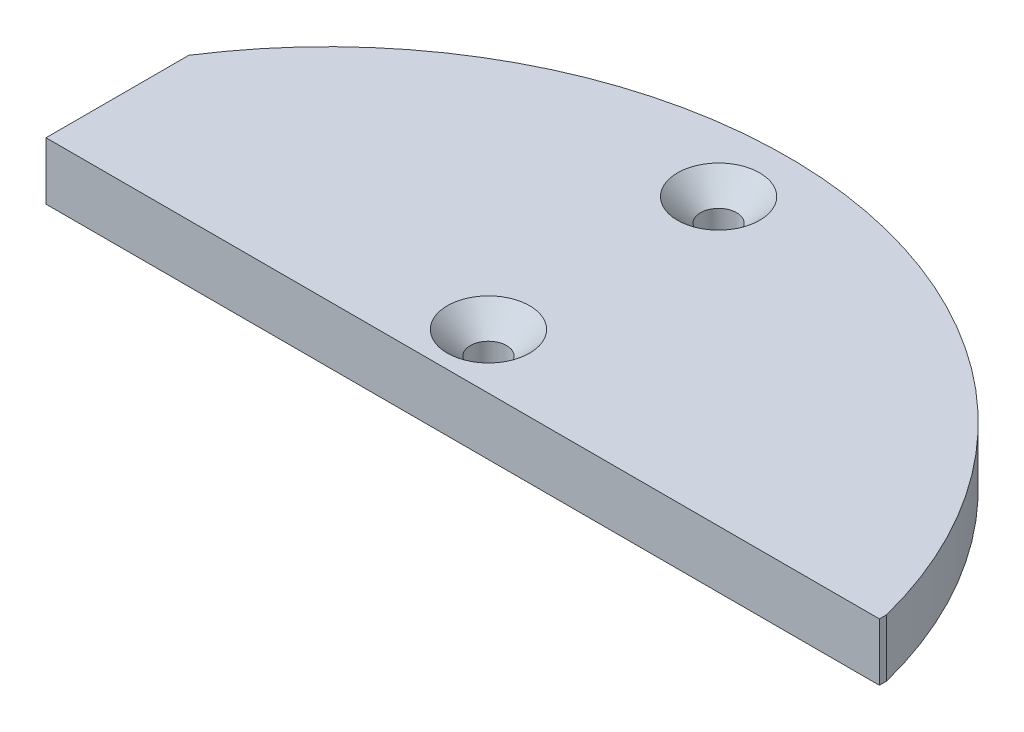
from build123d import *

# Parameters (mm, degrees)
SKETCH1_R           = 2
BOSS_EXTRUDE1_DEPTH = 6.35
CHAMFER1_SIZE       = 2.54
CUT_EXTRUDE1_DEPTH  = 4.7625
FILLET1_R           = 4
FILLET2_R           = 2


with BuildPart() as part:
    # Sketch1 → Boss-Extrude1 (new body)
    with BuildSketch(Plane(origin=(0, 0, 0), x_dir=(1, 0, 0), z_dir=(0, 1, 0))):
        with BuildLine():
            Line((-42.746, 11.684), (47.586884748, 11.684))
            Line((47.586884748, 11.684), (47.586884748, 17.78))
            ThreePointArc((47.586884748, 17.78), (31.011055518, 40.236232871), (5.073646026, 50.546))
            Line((5.073646026, 50.546), (-5.073646026, 50.546))
            ThreePointArc((-5.073646026, 50.546), (-26.552841725, 43.308043091), (-42.746, 27.448487827))
            Line((-42.746, 27.448487827), (-42.746, 11.684))
        make_face()
        with Locations((0, 17.78)):
            Circle(SKETCH1_R, mode=Mode.SUBTRACT)
        with Locations((0, 43.18)):
            Circle(SKETCH1_R, mode=Mode.SUBTRACT)
        with BuildLine():
            Line((47.586884748, 17.78), (47.586884748, 11.684))
            Line((47.586884748, 11.684), (49.243425186, 11.684))
            Line((49.243425186, 11.684), (49.243425186, 12.478985375))
            ThreePointArc((49.243425186, 12.478985375), (48.487652237, 15.15214772), (47.586884748, 17.78))
        make_face()
        with BuildLine():
            Line((-5.073646026, 50.546), (5.073646026, 50.546))
            ThreePointArc((5.073646026, 50.546), (2.539999948, 50.736460265), (-1.05e-07, 50.8))
            ThreePointArc((-1.05e-07, 50.8), (-2.540000052, 50.73646026), (-5.073646026, 50.546))
        make_face()
    extrude(amount=BOSS_EXTRUDE1_DEPTH)

    # Chamfer1
    chamfer1_edges = [part.edges().sort_by_distance(p)[0] for p in [
        (-2, 6.35, -17.78),
        (-2, 6.35, -43.18),
    ]]
    chamfer(chamfer1_edges, length=CHAMFER1_SIZE)

    # Sketch2 → Cut-Extrude1 (cut)
    with BuildSketch(Plane.XZ):
        with BuildLine():
            ThreePointArc((4.836612521, -48.974251761), (31.631563601, -37.700322816), (47.389212317, -13.2715))
            Line((47.389212317, -13.2715), (5.450452083, -13.2715))
            ThreePointArc((5.450452083, -13.2715), (3.766359845, -14.192688904), (3.633634696, -16.107666631))
            ThreePointArc((3.633634696, -16.107666631), (1e-09, -21.78), (-3.633634697, -16.107666633))
            ThreePointArc((-3.633634697, -16.107666633), (-3.766359842, -14.192688907), (-5.450452076, -13.2715))
            Line((-5.450452076, -13.2715), (-41.1585, -13.2715))
            Line((-41.1585, -13.2715), (-41.1585, -26.978658862))
            ThreePointArc((-41.1585, -26.978658862), (-25.491942293, -42.09549898), (-4.836612574, -48.974251756))
            ThreePointArc((-4.836612574, -48.974251756), (-2.876580864, -47.927421723), (-3.093368257, -45.715955999))
            ThreePointArc((-3.093368257, -45.715955999), (1e-09, -39.18), (3.093368255, -45.715956001))
            ThreePointArc((3.093368255, -45.715956001), (2.876580852, -47.927421701), (4.836612521, -48.974251761))
        make_face()
    extrude(amount=-CUT_EXTRUDE1_DEPTH, mode=Mode.SUBTRACT)

    # Fillet1
    fillet1_edges = [part.edges().sort_by_distance(p)[0] for p in [
        (47.389212317, 2.38125, -13.2715),
        (-41.1585, 2.38125, -13.2715),
        (-41.1585, 2.38125, -26.978658862),
    ]]
    fillet(fillet1_edges, radius=FILLET1_R)

    # Fillet2
    fillet2_edges = [part.edges().sort_by_distance(p)[0] for p in [
        (1e-09, 4.7625, -21.78),
        (1e-09, 4.7625, -39.18),
        (-2.876580864, 4.7625, -47.927421723),
        (2.876580852, 4.7625, -47.927421701),
        (29.335536204, 4.7625, -39.513244259),
        (3.766359845, 4.7625, -14.192688904),
        (-3.766359842, 4.7625, -14.192688907),
        (-21.304476038, 4.7625, -13.2715),
        (23.617003395, 4.7625, -13.2715),
        (-24.944627959, 4.7625, -42.422113246),
        (-41.1585, 4.7625, -21.514181912),
        (-39.986927125, 4.7625, -14.443072875),
        (-40.976209704, 4.7625, -26.950636255),
        (45.108619745, 4.7625, -15.048002194),
    ]]
    fillet(fillet2_edges, radius=FILLET2_R)


solid = part.part
